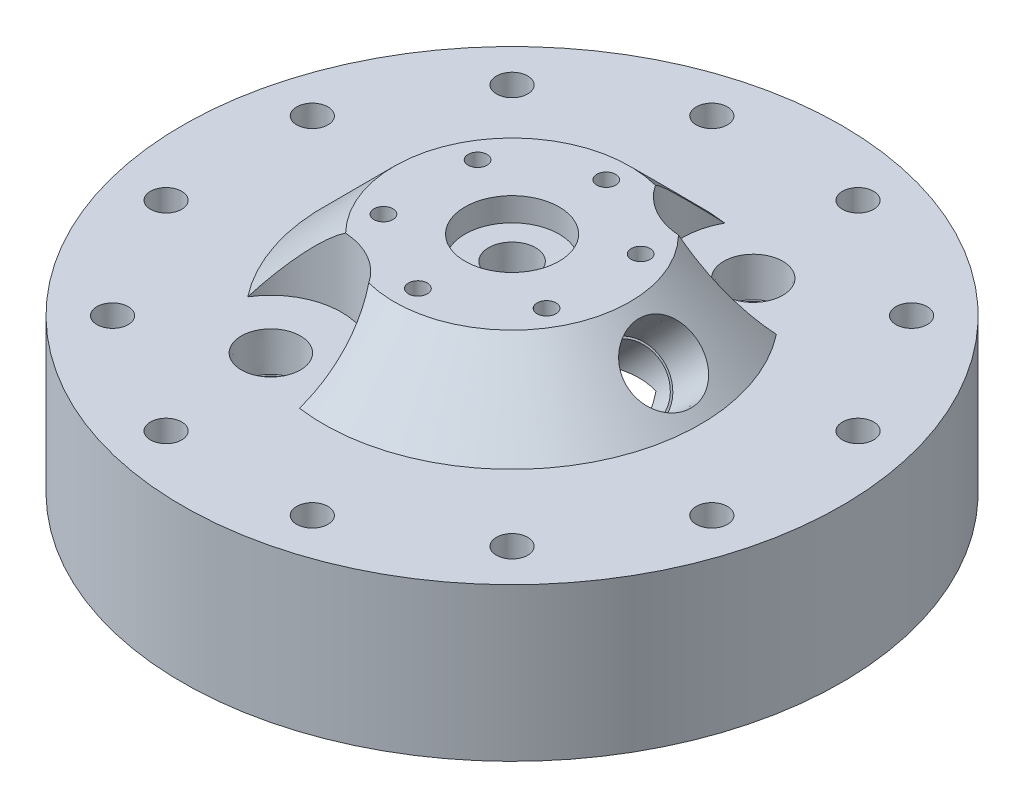
from build123d import *

# Parameters (mm, degrees)
F_5_16_CLEARANCE_HOLE1_D         = 8.4328
CIRPATTERN1_COUNT                = 12
F_1_2_0_5_DIAMETER_HOLE1_D       = 12.7
F_1_1_5_DIAMETER_HOLE1_D         = 38.1
F_1_1_5_DIAMETER_HOLE1_DEPTH     = 19.05
CIRPATTERN2_COUNT                = 6
CIRPATTERN3_COUNT                = 2
F_1_8_0_125_DIAMETER_HOLE1_D     = 3.175
F_1_8_0_125_DIAMETER_HOLE1_DEPTH = 6.35
F_1_8_0_125_DIAMETER_HOLE1_TIP   = 0.953866233


with BuildPart() as part:
    # Sketch1 → Revolve1 (revolve)
    with BuildSketch(Plane.XY, mode=Mode.PRIVATE) as revolve1_sk:
        Polygon((-88.9, 0), (-88.9, 41.275), (-50.8, 41.275), (-31.75, 60.325), (-12.7, 60.325), (-12.7, 53.975), (0, 53.975), (0, 34.925), (-31.75, 34.925), (-31.75, 22.225), (-50.8, 22.225), (-50.8, 3.175), (-52.3875, 3.175), (-52.3875, 5.715), (-55.9435, 5.715), (-55.9435, 3.175), (-57.15, 3.175), (-57.15, 0), align=None)
    revolve(revolve1_sk.sketch.rotate(Axis((0, 0, 0), (0, 1, 0)), 270), axis=Axis((0, 0, 0), (0, 1, 0)))

    # 5/16 Clearance Hole1 (through all)
    with Locations(Plane(origin=(0, 41.275, 0), x_dir=(1, 0, 0), z_dir=(0, 1, 0))):
        with Locations((-73.603547963, -19.722011237)):
            f_5_16_clearance_hole1 = Hole(F_5_16_CLEARANCE_HOLE1_D / 2)

    # CirPattern1: 5/16 Clearance Hole1 ×12 about axis
    cirpattern1_axis = Axis((0, 0, 0), (0, 1, 0))
    for i in range(1, CIRPATTERN1_COUNT):
        add(f_5_16_clearance_hole1.rotate(cirpattern1_axis, i * 360 / CIRPATTERN1_COUNT), mode=Mode.SUBTRACT)

    # 1/2 (0.5) Diameter Hole1 (through all)
    with Locations(Plane(origin=(0, 60.325, 0), x_dir=(1, 0, 0), z_dir=(0, 1, 0))):
        with Locations((0, 0)):
            Hole(F_1_2_0_5_DIAMETER_HOLE1_D / 2)

    # Sketch11 → 1/2 NPT Tapped Hole1 (revolve, cut)
    with BuildSketch(Plane(origin=(41.275, 50.8, 0), x_dir=(-0.707106781186546, 0.707106781186549, 0), z_dir=(0, 0, 1))):
        Polygon((0, 0), (0, 127.968649725), (8.9281, 127.968649725), (8.9281, 13.462), (9.479726792, 13.462), (9.8827971, 0), align=None)
    revolve(axis=Axis((45.765128061, 55.290128061, 0), (-0.707106781186549, -0.707106781186546, 0)), mode=Mode.SUBTRACT)

    # 1 (1.5) Diameter Hole1
    with Locations(Plane(origin=(0, 60.325, 0), x_dir=(1, 0, 0), z_dir=(0, 1, 0))):
        with Locations((-23.8125, -41.244459855)):
            f_1_1_5_diameter_hole1 = Hole(F_1_1_5_DIAMETER_HOLE1_D / 2, depth=F_1_1_5_DIAMETER_HOLE1_DEPTH)

    # Sketch19 → 3/8 NPT Tapped Hole1 (revolve, cut)
    with BuildSketch(Plane(origin=(-23.8125, 41.275, 41.244459855), x_dir=(0, 0, 1), z_dir=(1, 0, 0))):
        Polygon((0, 0), (0, 26.640582582), (7.1374, 22.352), (7.1374, 10.414), (7.653732494, 10.414), (7.9655416, 0), align=None)
    f_3_8_npt_tapped_hole1 = revolve(axis=Axis((-23.8125, 47.625, 41.244459855), (0, -1, 0)), mode=Mode.SUBTRACT)

    # Sketch21 → Tap Drill for 1/4-20 Tap1 (revolve, cut)
    with BuildSketch(Plane(origin=(21.997045256, 60.325, -12.7), x_dir=(0, 0, 1), z_dir=(1, 0, 0))):
        Polygon((0, 0), (0, 17.535816902), (2.5527, 16.002), (2.5527, 0), align=None)
    tap_drill_for_1_4_20_tap1 = revolve(axis=Axis((21.997045256, 66.675, -12.7), (0, -1, 0)), mode=Mode.SUBTRACT)

    # CirPattern2: Tap Drill for 1/4-20 Tap1 ×6 about axis
    cirpattern2_axis = Axis((0, 0, 0), (0, 1, 0))
    for i in range(1, CIRPATTERN2_COUNT):
        add(tap_drill_for_1_4_20_tap1.rotate(cirpattern2_axis, i * 360 / CIRPATTERN2_COUNT), mode=Mode.SUBTRACT)

    # CirPattern3: 1 (1.5) Diameter Hole1, 3/8 NPT Tapped Hole1 ×2 about axis
    cirpattern3_axis = Axis((0, 0, 0), (0, 1, 0))
    add([f_1_1_5_diameter_hole1.rotate(cirpattern3_axis, i * 360 / CIRPATTERN3_COUNT) for i in range(1, CIRPATTERN3_COUNT)], mode=Mode.SUBTRACT)
    add([f_3_8_npt_tapped_hole1.rotate(cirpattern3_axis, i * 360 / CIRPATTERN3_COUNT) for i in range(1, CIRPATTERN3_COUNT)], mode=Mode.SUBTRACT)

    # 1/8 (0.125) Diameter Hole1
    with Locations(Plane(origin=(0, 22.225, 0), x_dir=(-1, 0, 0), z_dir=(0, -1, 0))):
        with Locations((0, 44.45)):
            Hole(F_1_8_0_125_DIAMETER_HOLE1_D / 2, depth=F_1_8_0_125_DIAMETER_HOLE1_DEPTH)
            with Locations((0, 0, -(F_1_8_0_125_DIAMETER_HOLE1_DEPTH + F_1_8_0_125_DIAMETER_HOLE1_TIP / 2))):  # 118° drill point
                Cone(0, F_1_8_0_125_DIAMETER_HOLE1_D / 2, F_1_8_0_125_DIAMETER_HOLE1_TIP, mode=Mode.SUBTRACT)


solid = part.part
